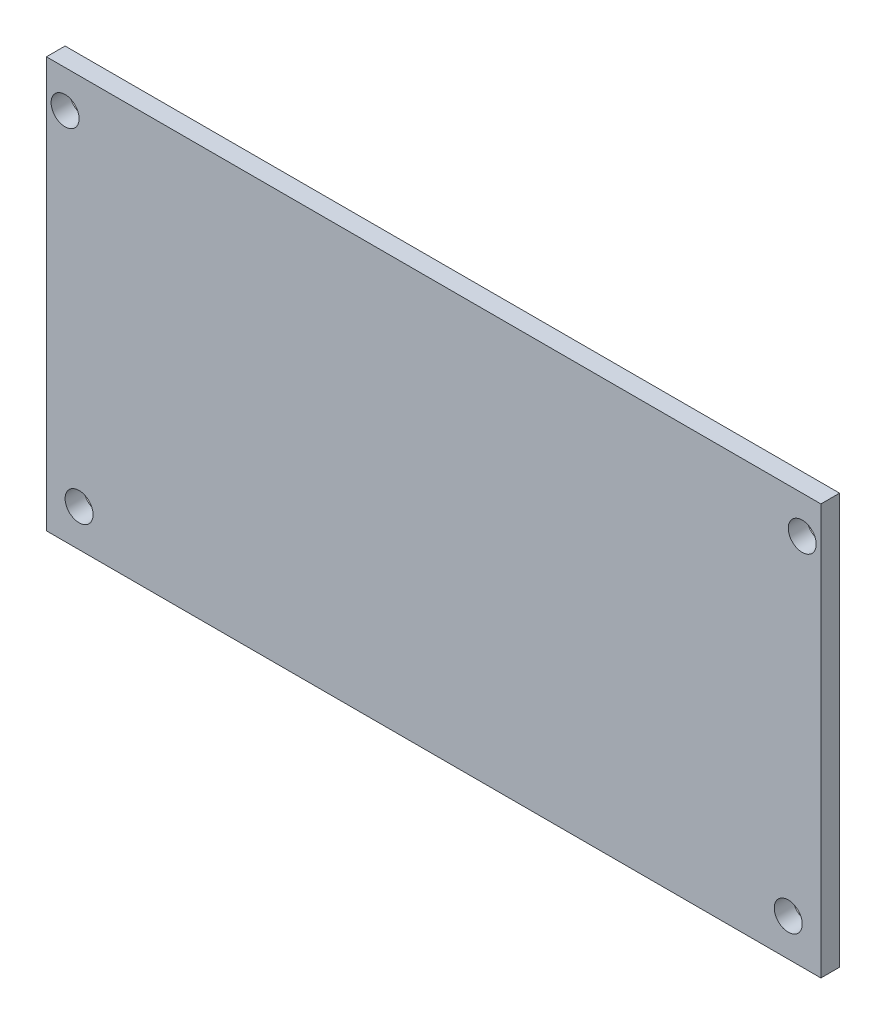
from build123d import *

# Parameters (mm, degrees)
ESQUISSE1_W             = 83
ESQUISSE1_H             = 44
EXTRUSION1_DEPTH        = 2
ESQUISSE2_R             = 1.5
ENL_V_MAT_EXTRU_1_DEPTH = 10


with BuildPart() as part:
    # Esquisse1 → Extrusion1 (new body)
    with BuildSketch(Plane.XY):
        with Locations((-41.5, 22)):
            Rectangle(ESQUISSE1_W, ESQUISSE1_H)
    extrude(amount=EXTRUSION1_DEPTH)

    # Esquisse2 → Enlèv. mat.-Extru.1 (cut)
    with BuildSketch(Plane.XY.offset(2)):
        with Locations((-81, 40)):
            Circle(ESQUISSE2_R)
        with Locations((-79.5, 4)):
            Circle(ESQUISSE2_R)
        with Locations((-3.5, 4)):
            Circle(ESQUISSE2_R)
        with Locations((-2, 40)):
            Circle(ESQUISSE2_R)
    extrude(amount=-ENL_V_MAT_EXTRU_1_DEPTH, mode=Mode.SUBTRACT)


solid = part.part
